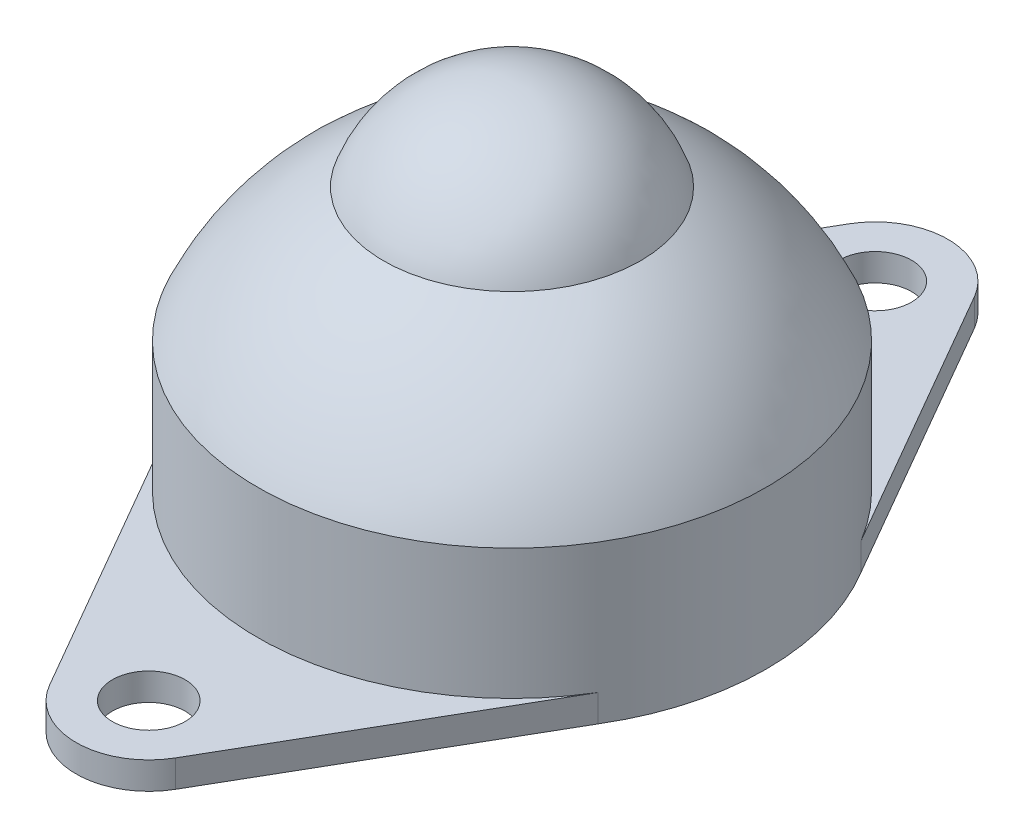
from build123d import *

# Parameters (mm, degrees)
SKETCH_2_R      = 2
EXTRUDE_1_DEPTH = 1.5


with BuildPart() as part:
    # 草图1 → 旋转1 (revolve)
    with BuildSketch(Plane.XY):
        with BuildLine():
            Line((0, 0), (-14, 0))
            Line((-14, 0), (-14, 8.666286))
            ThreePointArc((-14, 8.666286), (-11.155416, 12.918811), (-7.071068, 16))
            ThreePointArc((-7.071068, 16), (-4.330127, 19.623724), (0, 21))
            Line((0, 21), (0, 0))
        make_face()
    revolve(axis=Axis((0, 0, 0), (0, 1, 0)))

    # 草图2 → 凸台-拉伸1 (add)
    with BuildSketch(Plane(origin=(0, 0, 0), x_dir=(1, 0, 0), z_dir=(0, 1, 0))):
        with BuildLine():
            Line((3.464435, 21.999422), (11.980808, 7.242943))
            ThreePointArc((11.980808, 7.242943), (14, 0), (11.980808, -7.242943))
            Line((11.980808, -7.242943), (3.464435, -21.999422))
            ThreePointArc((3.464435, -21.999422), (0, -24), (-3.464435, -21.999422))
            Line((-3.464435, -21.999422), (-11.980808, -7.242943))
            ThreePointArc((-11.980808, -7.242943), (-14, 0), (-11.980808, 7.242943))
            Line((-11.980808, 7.242943), (-3.464435, 21.999422))
            ThreePointArc((-3.464435, 21.999422), (0, 24), (3.464435, 21.999422))
        make_face()
        with Locations((0, 20)):
            Circle(SKETCH_2_R, mode=Mode.SUBTRACT)
        with Locations((0, -20)):
            Circle(SKETCH_2_R, mode=Mode.SUBTRACT)
    extrude(amount=EXTRUDE_1_DEPTH)


solid = part.part
